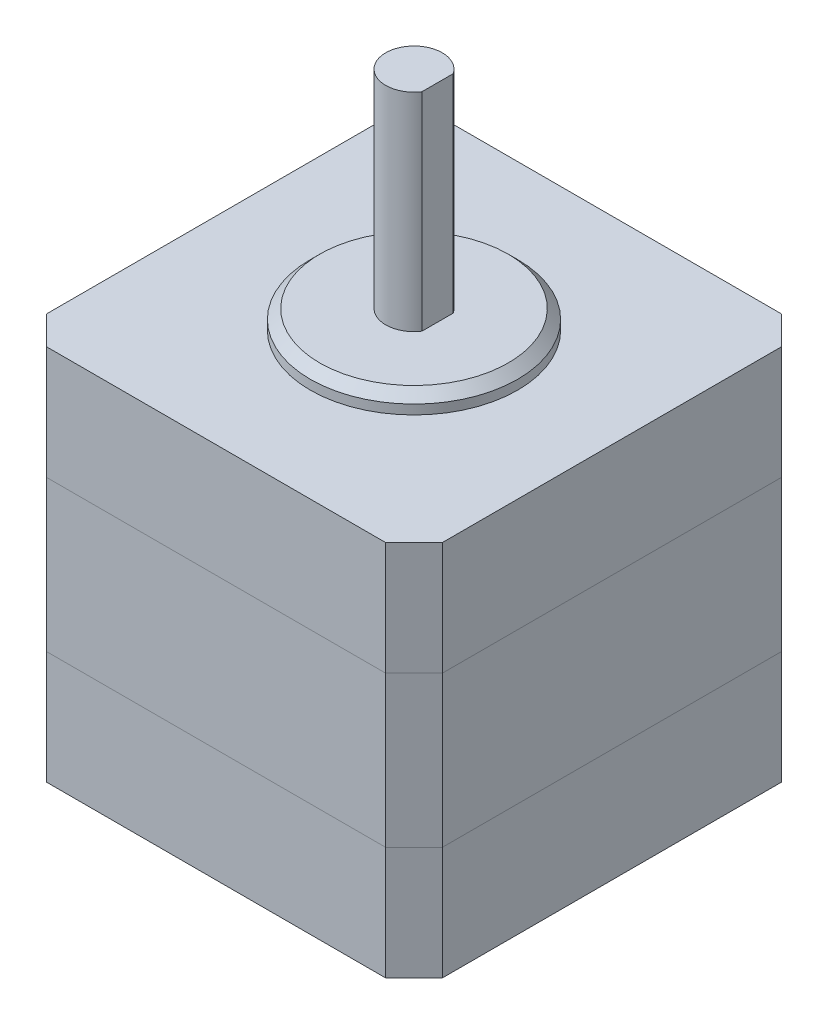
from build123d import *

# Parameters (mm, degrees)
SKETCH1_W           = 42
SKETCH1_H           = 42
BOSS_EXTRUDE1_DEPTH = 40
CHAMFER2_SIZE       = 3
SKETCH2_R           = 11
BOSS_EXTRUDE2_DEPTH = 2
BOSS_EXTRUDE3_DEPTH = 22
CHAMFER3_SIZE       = 1


with BuildPart() as part:
    # Sketch1 → Boss-Extrude1 (new body)
    with BuildSketch(Plane(origin=(0, 0, 0), x_dir=(1, 0, 0), z_dir=(0, 1, 0))):
        Rectangle(SKETCH1_W, SKETCH1_H)
    extrude(amount=BOSS_EXTRUDE1_DEPTH)

    # Chamfer2
    chamfer2_edges = [part.edges().sort_by_distance(p)[0] for p in [
        (21, 20, 21),
        (-21, 20, 21),
        (-21, 20, -21),
        (21, 20, -21),
    ]]
    chamfer(chamfer2_edges, length=CHAMFER2_SIZE)

    # Sketch2 → Boss-Extrude2 (add)
    with BuildSketch(Plane(origin=(0, 40, 0), x_dir=(1, 0, 0), z_dir=(0, 1, 0))):
        Circle(SKETCH2_R)
    extrude(amount=BOSS_EXTRUDE2_DEPTH)

    # Sketch3 → Boss-Extrude3 (add)
    with BuildSketch(Plane(origin=(0, 42, 0), x_dir=(1, 0, 0), z_dir=(0, 1, 0))):
        with BuildLine():
            Line((2.5, 1.658312395), (2.5, -1.658312395))
            ThreePointArc((2.5, -1.658312395), (-3, 0), (2.5, 1.658312395))
        make_face()
    extrude(amount=BOSS_EXTRUDE3_DEPTH)

    # Chamfer3
    chamfer3_edges = [part.edges().sort_by_distance(p)[0] for p in [
        (-11, 42, 0),
    ]]
    chamfer(chamfer3_edges, length=CHAMFER3_SIZE)


solid = part.part
